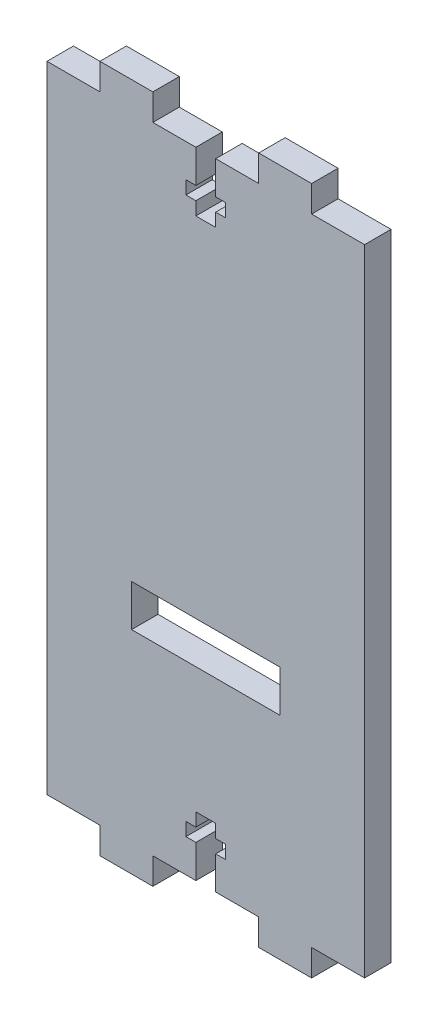
from build123d import *

# Parameters (mm, degrees)
SKETCH2_W           = 30
SKETCH2_H           = 10
BOSS_EXTRUDE1_DEPTH = 6.35
SKETCH3_W           = 35.56
SKETCH3_H           = 10
CUT_EXTRUDE1_DEPTH  = 6.35


with BuildPart() as part:
    # Sketch2 → Boss-Extrude1 (new body)
    with BuildSketch(Plane.XY):
        Polygon((12.244662888, 165.1), (24.944662888, 165.1), (24.944662888, 158.75), (35.263412888, 158.75), (35.263412888, 150.8125), (32.882162888, 150.8125), (32.882162888, 147.6375), (35.263412888, 147.6375), (35.263412888, 144.4625), (40.025912888, 144.4625), (40.025912888, 147.6375), (42.407162888, 147.6375), (42.407162888, 150.8125), (40.025912888, 150.8125), (40.025912888, 158.75), (50.344662888, 158.75), (50.344662888, 165.1), (63.044662888, 165.1), (63.044662888, 158.75), (75.744662888, 158.75), (75.744662888, 6.35), (63.044662888, 6.35), (63.044662888, 0), (50.344662888, 0), (50.344662888, 6.35), (40.025912888, 6.35), (40.025912888, 14.2875), (42.407162888, 14.2875), (42.407162888, 17.4625), (40.025912888, 17.4625), (40.025912888, 20.6375), (35.263412888, 20.6375), (35.263412888, 17.4625), (32.882162888, 17.4625), (32.882162888, 14.2875), (35.263412888, 14.2875), (35.263412888, 6.35), (24.944662888, 6.35), (24.944662888, 0), (12.244662888, 0), (12.244662888, 6.35), (-0.455337112, 6.35), (-0.455337112, 158.75), (12.244662888, 158.75), align=None)
        with Locations((37.644662886, 55.8)):
            Rectangle(SKETCH2_W, SKETCH2_H, mode=Mode.SUBTRACT)
    extrude(amount=BOSS_EXTRUDE1_DEPTH)

    # Sketch3 → Cut-Extrude1 (cut)
    with BuildSketch(Plane.XY.offset(6.35)):
        with Locations((37.623375509, 55.8)):
            Rectangle(SKETCH3_W, SKETCH3_H)
    extrude(amount=-CUT_EXTRUDE1_DEPTH, mode=Mode.SUBTRACT)


solid = part.part
